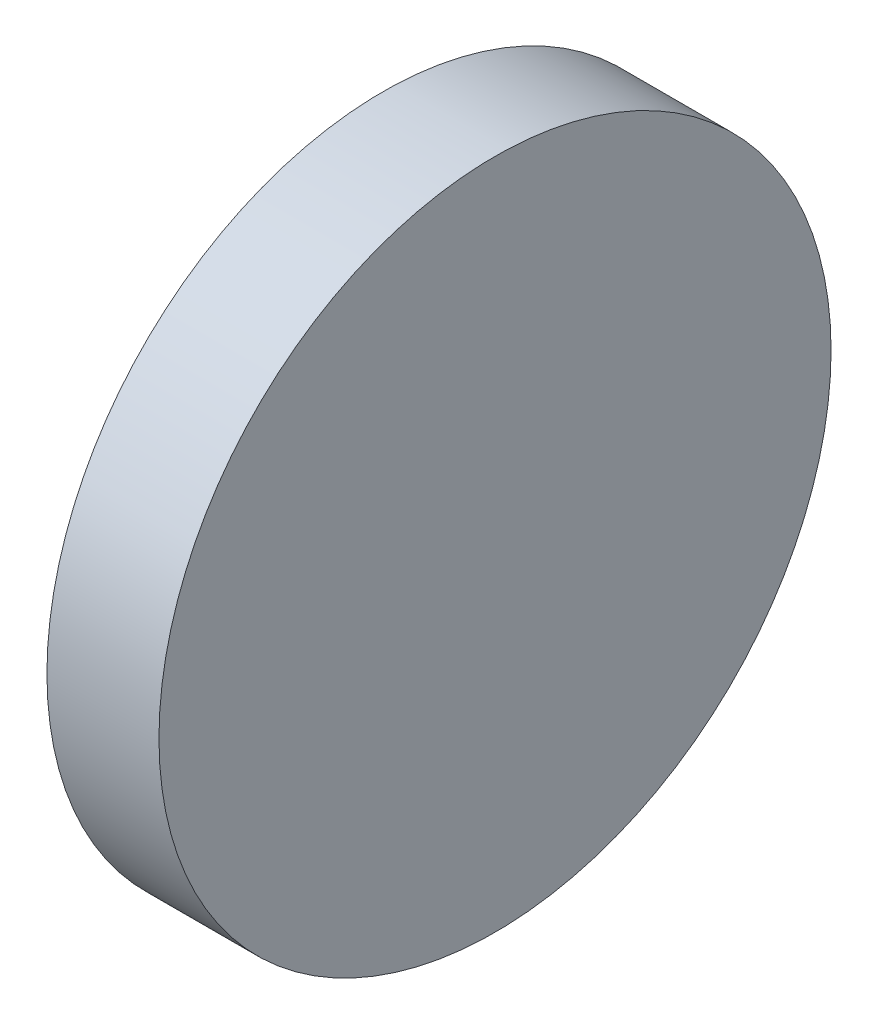
from build123d import *

# Parameters (mm, degrees)
SKETCH_1_W = 1
SKETCH_1_H = 3


with BuildPart() as part:
    # 草图1 → 旋转2 (revolve)
    with BuildSketch(Plane.XY, mode=Mode.PRIVATE) as revolve_2_sk:
        with Locations((0.5, 1.5)):
            Rectangle(SKETCH_1_W, SKETCH_1_H)
    revolve(revolve_2_sk.sketch.rotate(Axis((0, 0, 0), (1, 0, 0)), 90), axis=Axis((0, 0, 0), (1, 0, 0)))  # turned: the seam where the file's is


solid = part.part
